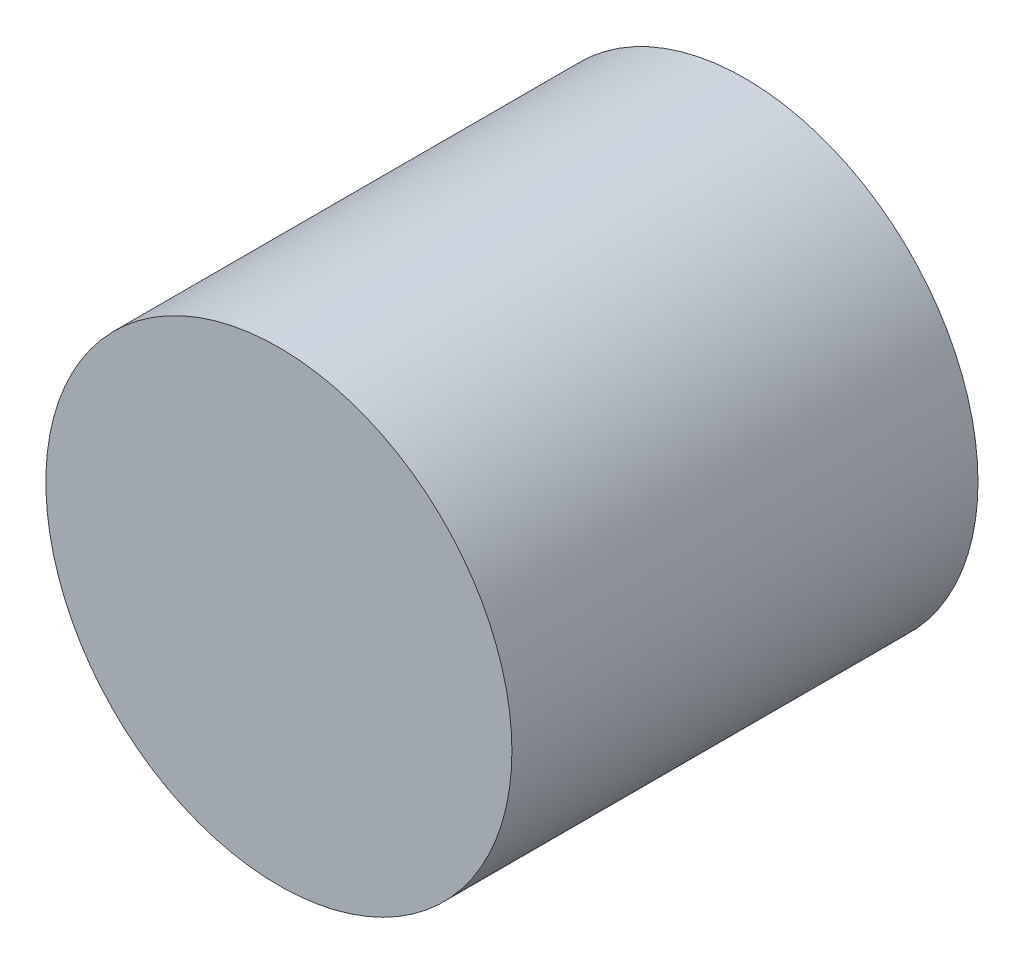
from build123d import *

# Parameters (mm, degrees)
SKETCH1_R           = 5
BOSS_EXTRUDE1_DEPTH = 10


with BuildPart() as part:
    # Sketch1 → Boss-Extrude1 (new body)
    with BuildSketch(Plane.XY):
        Circle(SKETCH1_R)
    extrude(amount=BOSS_EXTRUDE1_DEPTH)


solid = part.part
